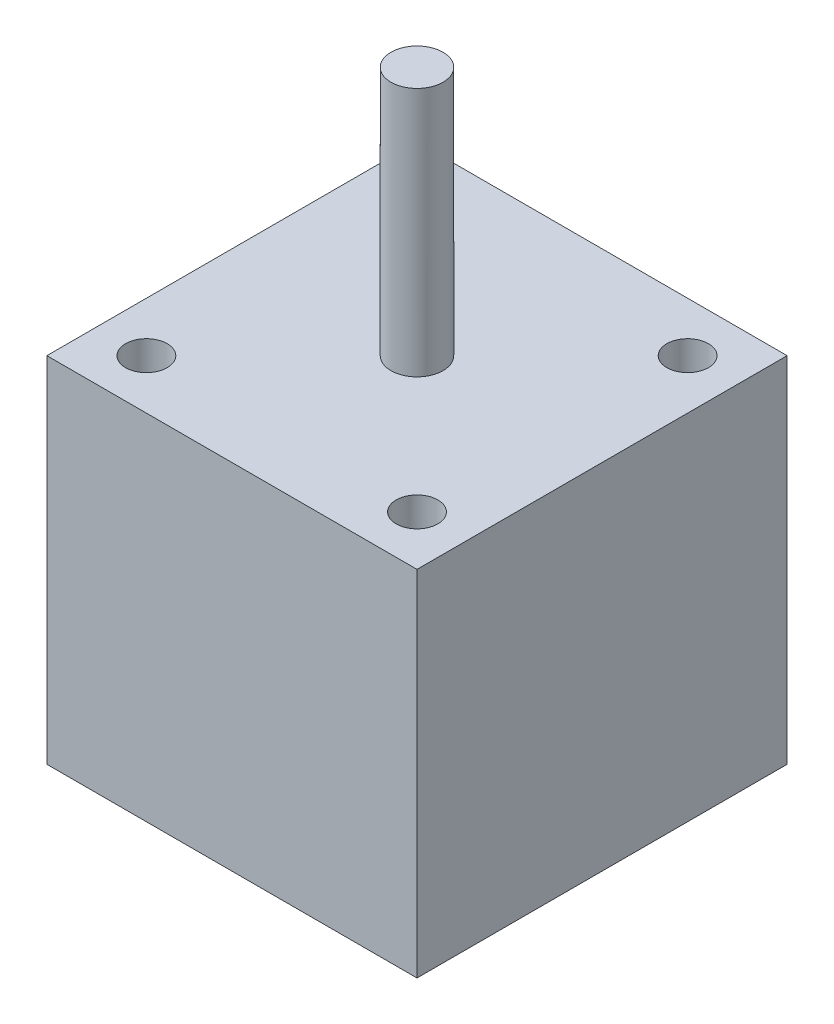
from build123d import *

# Parameters (mm, degrees)
SKETCH1_W           = 35.56
SKETCH1_H           = 35.56
BOSS_EXTRUDE1_DEPTH = 34
SKETCH2_R           = 2.5
BOSS_EXTRUDE2_DEPTH = 24
SKETCH3_R           = 2.5
BOSS_EXTRUDE3_DEPTH = 12
SKETCH4_R           = 2
CUT_EXTRUDE1_DEPTH  = 34


with BuildPart() as part:
    # Sketch1 → Boss-Extrude1 (new body)
    with BuildSketch(Plane(origin=(0, 0, 0), x_dir=(1, 0, 0), z_dir=(0, 1, 0))):
        Rectangle(SKETCH1_W, SKETCH1_H)
    extrude(amount=BOSS_EXTRUDE1_DEPTH)

    # Sketch2 → Boss-Extrude2 (add)
    with BuildSketch(Plane(origin=(0, 34, 0), x_dir=(1, 0, 0), z_dir=(0, 1, 0))):
        Circle(SKETCH2_R)
    extrude(amount=BOSS_EXTRUDE2_DEPTH)

    # Sketch3 → Boss-Extrude3 (add)
    with BuildSketch(Plane.XZ):
        Circle(SKETCH3_R)
    extrude(amount=BOSS_EXTRUDE3_DEPTH)

    # Sketch4 → Cut-Extrude1 (cut)
    with BuildSketch(Plane(origin=(0, 34, 0), x_dir=(1, 0, 0), z_dir=(0, 1, 0))):
        with Locations((-13, 13)):
            Circle(SKETCH4_R)
        with Locations((13, 13)):
            Circle(SKETCH4_R)
        with Locations((13, -13)):
            Circle(SKETCH4_R)
        with Locations((-13, -13)):
            Circle(SKETCH4_R)
    extrude(amount=-CUT_EXTRUDE1_DEPTH, mode=Mode.SUBTRACT)


solid = part.part
